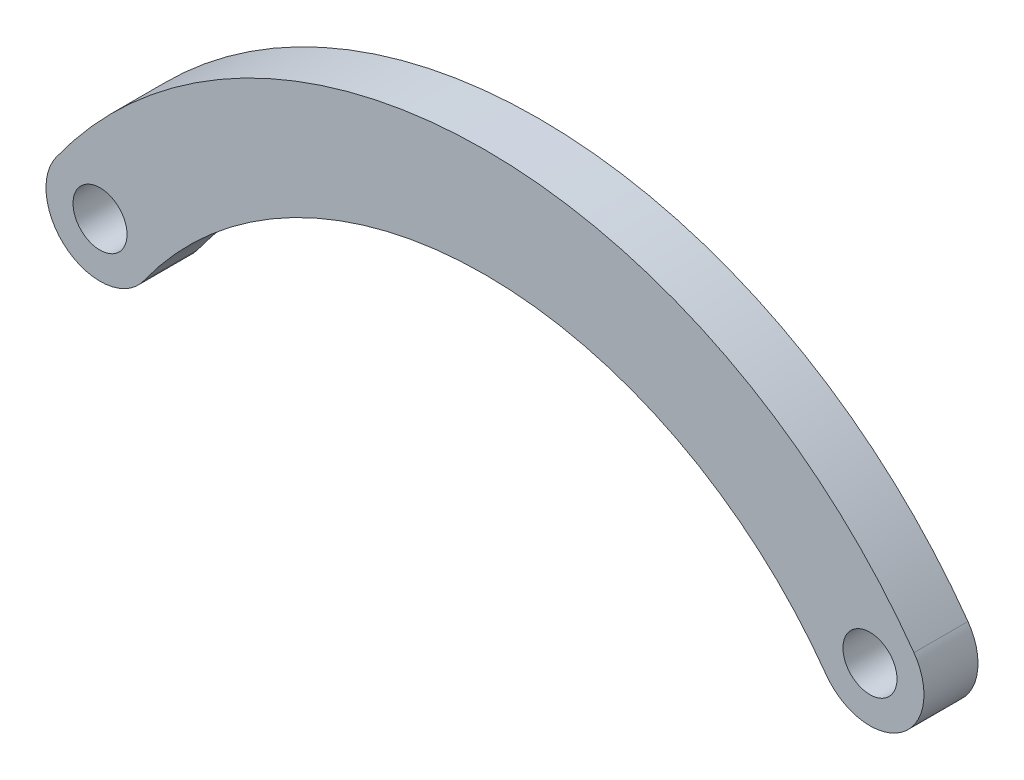
from build123d import *

# Parameters (mm, degrees)
SKETCH_1_R      = 2
EXTRUDE_1_DEPTH = 2


with BuildPart() as part:
    # 草图1 → 凸台-拉伸1 (new body, symmetric)
    with BuildSketch(Plane.XY):
        with BuildLine():
            ThreePointArc((-25.242857143, -2.321857103), (0, 10.683750346), (25.242857143, -2.321857103))
            ThreePointArc((25.242857143, -2.321857103), (30.821857103, -3.257142857), (31.757142857, 2.321857103))
            ThreePointArc((31.757142857, 2.321857103), (0, 18.683750346), (-31.757142857, 2.321857103))
            ThreePointArc((-31.757142857, 2.321857103), (-30.821857103, -3.257142857), (-25.242857143, -2.321857103))
        make_face()
        with Locations((28.5, 0)):
            Circle(SKETCH_1_R, mode=Mode.SUBTRACT)
        with Locations((-28.5, 0)):
            Circle(SKETCH_1_R, mode=Mode.SUBTRACT)
    extrude(amount=EXTRUDE_1_DEPTH, both=True)


solid = part.part
